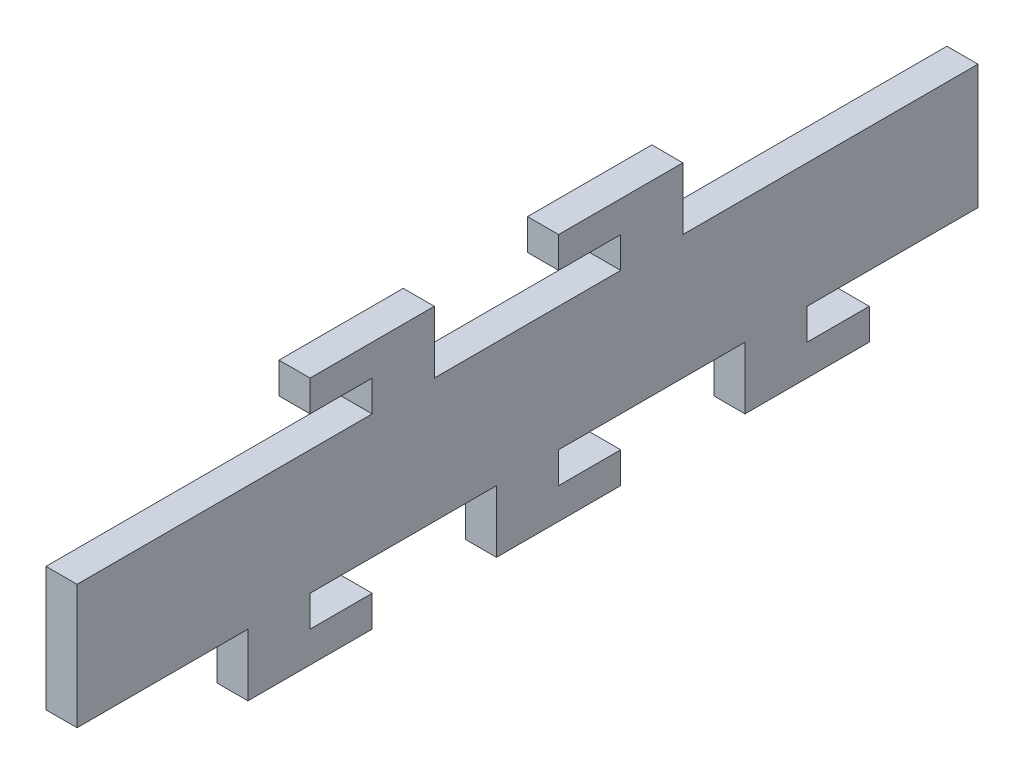
from build123d import *

# Parameters (mm, degrees)
BOSS_EXTRU_1_DEPTH = 5


with BuildPart() as part:
    # Esquisse1 → Boss.-Extru.1 (new body)
    with BuildSketch(Plane(origin=(0, 0, 0), x_dir=(0, 0, -1), z_dir=(1, 0, 0))):
        Polygon((72.5, -10), (45, -10), (45, -15), (55, -15), (55, -20), (35, -20), (35, -10), (5, -10), (5, -15), (15, -15), (15, -20), (-5, -20), (-5, -10), (-35, -10), (-35, -15), (-25, -15), (-25, -20), (-45, -20), (-45, -10), (-72.5, -10), (-72.5, 10), (-25, 10), (-25, 15), (-35, 15), (-35, 20), (-15, 20), (-15, 10), (15, 10), (15, 15), (5, 15), (5, 20), (25, 20), (25, 10), (72.5, 10), align=None)
    extrude(amount=BOSS_EXTRU_1_DEPTH)


solid = part.part
